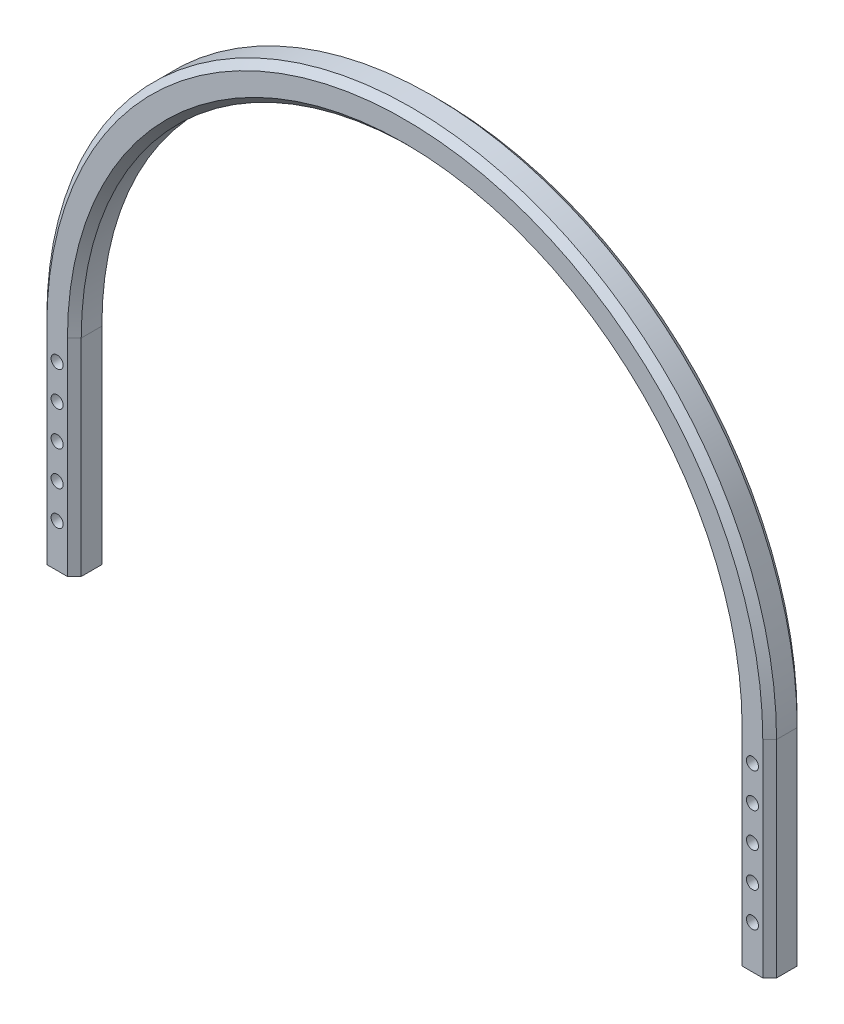
from build123d import *

# Parameters (mm, degrees)
BOSS_EXTRUDE1_DEPTH = 10
CHAMFER1_SIZE       = 2
SKETCH2_R           = 1.75
CUT_EXTRUDE1_DEPTH  = 11
LPATTERN1_COUNT     = 5
LPATTERN1_PITCH     = 10
SKETCH3_R           = 1.5
CUT_EXTRUDE2_DEPTH  = 10


with BuildPart() as part:
    # Sketch1 → Boss-Extrude1 (new body)
    with BuildSketch(Plane.XY):
        with BuildLine():
            Line((-106, 0), (-106, 60))
            ThreePointArc((-106, 60), (0, 166), (106, 60))
            Line((106, 60), (106, 0))
            Line((106, 0), (96, 0))
            Line((96, 0), (96, 60))
            ThreePointArc((96, 60), (0, 156), (-96, 60))
            Line((-96, 60), (-96, 0))
            Line((-96, 0), (-106, 0))
        make_face()
    extrude(amount=BOSS_EXTRUDE1_DEPTH)

    # Chamfer1
    chamfer1_edges = [part.edges().sort_by_distance(p)[0] for p in [
        (96, 30, 0),
        (0, 156, 0),
        (-96, 30, 0),
        (0, 156, 10),
        (96, 30, 10),
        (106, 30, 10),
        (0, 166, 10),
        (-106, 30, 10),
        (-106, 30, 0),
        (-96, 30, 10),
        (0, 166, 0),
        (106, 30, 0),
    ]]
    chamfer(chamfer1_edges, length=CHAMFER1_SIZE)

    # Sketch2 → Cut-Extrude1 (cut, through all)
    with BuildSketch(Plane.XY.offset(10)):
        with Locations((-101, 12.5)):
            Circle(SKETCH2_R)
        with Locations((101, 12.5)):
            Circle(SKETCH2_R)
    cut_extrude1 = extrude(amount=-CUT_EXTRUDE1_DEPTH, mode=Mode.SUBTRACT)

    # LPattern1: Cut-Extrude1 ×5
    with Locations(*[(0, i * LPATTERN1_PITCH, 0) for i in range(1, LPATTERN1_COUNT)]):
        add(cut_extrude1, mode=Mode.SUBTRACT)

    # Sketch3 → Cut-Extrude2 (cut)
    with BuildSketch(Plane.XZ):
        with Locations((-101, 5)):
            Circle(SKETCH3_R)
        with Locations((101, 5)):
            Circle(SKETCH3_R)
    extrude(amount=-CUT_EXTRUDE2_DEPTH, mode=Mode.SUBTRACT)


solid = part.part
